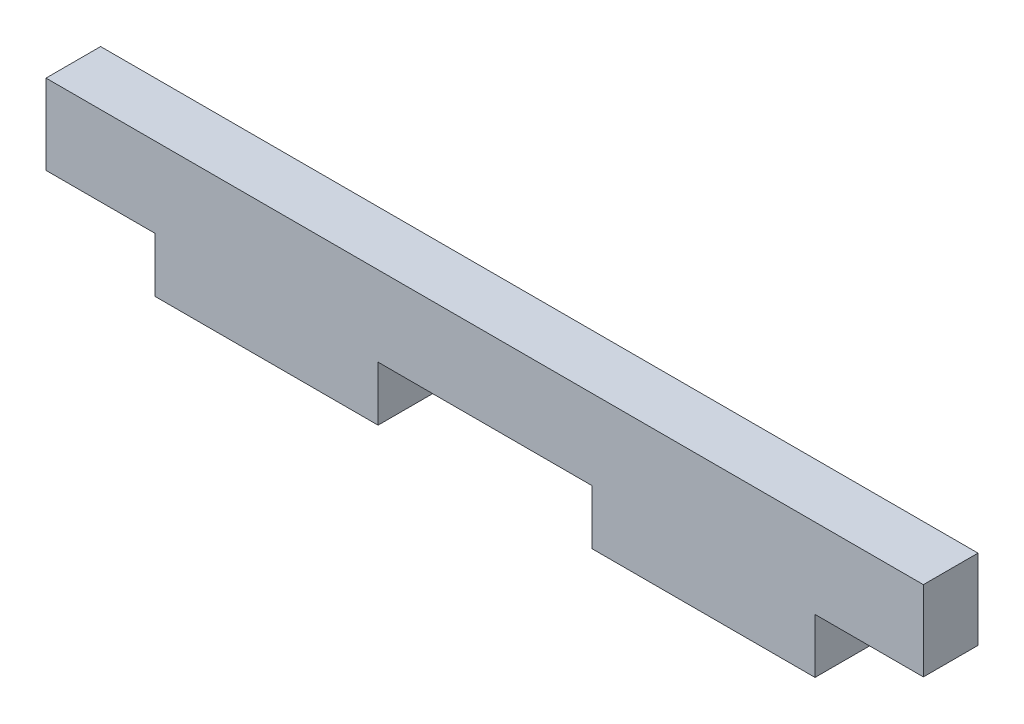
from build123d import *

# Parameters (mm, degrees)
BOSS_EXTRUDE1_DEPTH = 3.175


with BuildPart() as part:
    # Sketch1 → Boss-Extrude1 (new body)
    with BuildSketch(Plane.XY):
        Polygon((19.2024, -0.7366), (25.5016, -0.7366), (25.5016, 3.9116), (-25.5016, 3.9116), (-25.5016, -0.7366), (-19.1516, -0.7366), (-19.1516, -3.9116), (-6.1976, -3.9116), (-6.1976, -0.7366), (6.2484, -0.7366), (6.2484, -3.9116), (19.2024, -3.9116), align=None)
    extrude(amount=BOSS_EXTRUDE1_DEPTH)


solid = part.part
